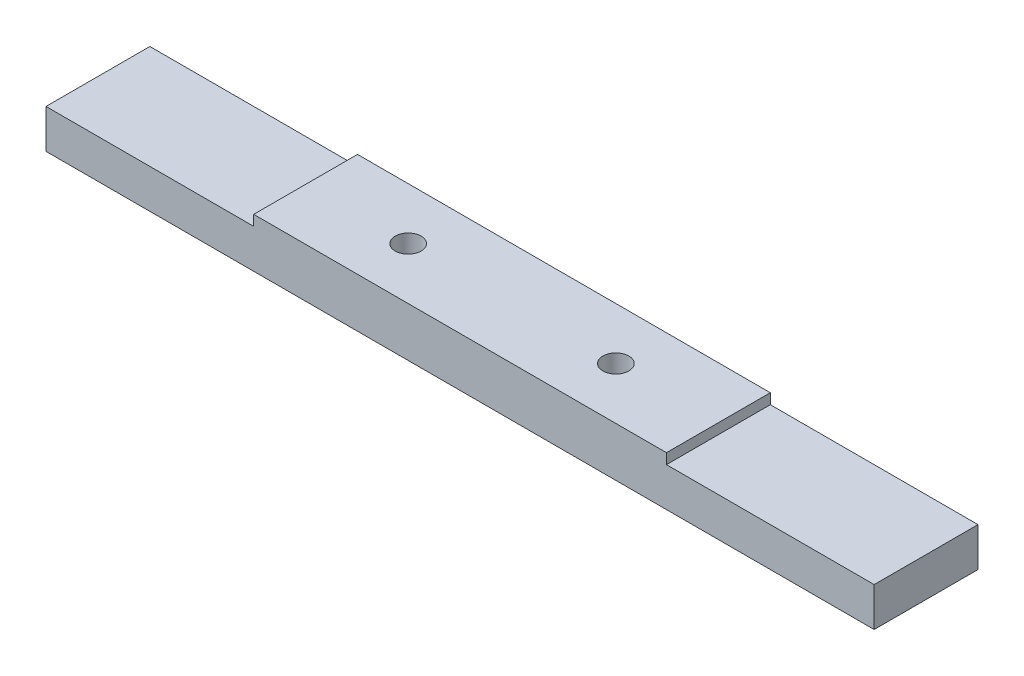
from build123d import *

# Parameters (mm, degrees)
AUFSATZ_LINEAR_AUSTRAGEN1_DEPTH                      = 4
FORMSENKUNG_F_R_M3_SENKSCHRAUBE_MIT_INNE_D           = 2
FORMSENKUNG_F_R_M3_SENKSCHRAUBE_MIT_INNE_CSINK_D     = 3.5
FORMSENKUNG_F_R_M3_SENKSCHRAUBE_MIT_INNE_CSINK_ANGLE = 90


with BuildPart() as part:
    # Skizze1 → Aufsatz-Linear austragen1 (new body, symmetric)
    with BuildSketch(Plane.XY):
        Polygon((-31.9, 0), (-15.9, 0), (-15.9, 0.8), (15.9, 0.8), (15.9, 0), (31.9, 0), (31.9, -3), (-31.9, -3), align=None)
    extrude(amount=AUFSATZ_LINEAR_AUSTRAGEN1_DEPTH, both=True)

    # Formsenkung für M3 Senkschraube mit Innensechskant1 (through all)
    with Locations(Plane(origin=(0, -3, 0), x_dir=(-1, 0, 0), z_dir=(0, -1, 0))):
        with Locations((8, 0), (-8, 0)):
            CounterSinkHole(FORMSENKUNG_F_R_M3_SENKSCHRAUBE_MIT_INNE_D / 2, FORMSENKUNG_F_R_M3_SENKSCHRAUBE_MIT_INNE_CSINK_D / 2, counter_sink_angle=FORMSENKUNG_F_R_M3_SENKSCHRAUBE_MIT_INNE_CSINK_ANGLE)


solid = part.part
